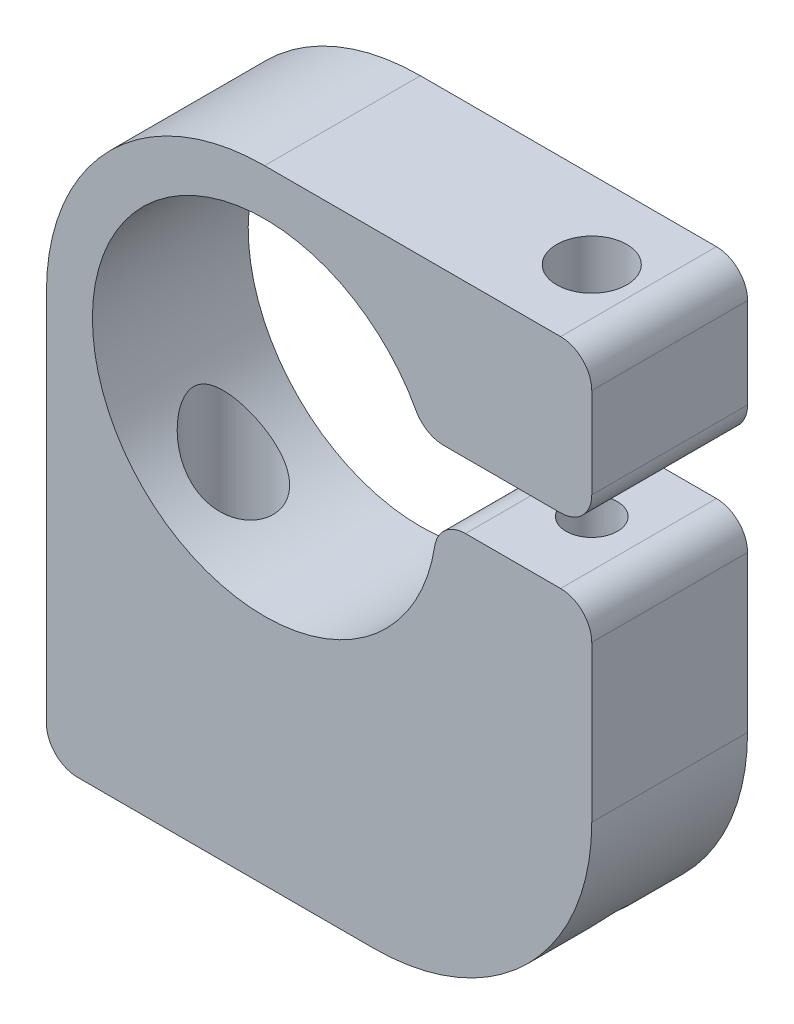
from build123d import *

# Parameters (mm, degrees)
EXTRUDE_1_DEPTH            = 10
HOLE_WIZARD_M41_D          = 4.5
HOLE_WIZARD_M41_DEPTH      = 9.8
M4X0_71_D                  = 3.3
HOLE_WIZARD_1_4_201_REACH  = 48.271
HOLE_WIZARD_1_4_201_BORE_R = 2.5527
FILLET_1_R                 = 2


with BuildPart() as part:
    # Эскиз1 → Бобышка-Вытянуть1 (new body)
    with BuildSketch(Plane.XY):
        with BuildLine():
            Line((10.220689801, 4.2), (21, 4.2))
            Line((21, 4.2), (21, 14))
            Line((21, 14), (0, 14))
            ThreePointArc((0, 14), (-9.899494937, 9.899494937), (-14, 0))
            Line((-14, 0), (-14, -26))
            Line((-14, -26), (7, -26))
            ThreePointArc((7, -26), (16.899494937, -21.899494937), (21, -12))
            Line((21, -12), (21, 0))
            Line((21, 0), (11.05, 0))
            ThreePointArc((11.05, 0), (-10.840690068, -2.140546391), (10.220689801, 4.2))
        make_face()
    extrude(amount=EXTRUDE_1_DEPTH)

    # Отверстие с зазором M41
    with Locations(Plane(origin=(0, 14, 0), x_dir=(1, 0, 0), z_dir=(0, 1, 0))):
        with Locations((16, -5)):
            Hole(HOLE_WIZARD_M41_D / 2, depth=HOLE_WIZARD_M41_DEPTH)

    # Отверстие обработанное метчиком M4x0.71 (through all)
    with Locations(Plane(origin=(0, 0, 0), x_dir=(1, 0, 0), z_dir=(0, 1, 0))):
        with Locations((16, -5)):
            Hole(M4X0_71_D / 2)

    # Отверстие обработанное метчиком 1/4-201 bore → Отверстие обработанное метчиком 1/4-201 (cut, up to next)
    with BuildSketch(Plane(origin=(0, -26, 0), x_dir=(-1, 0, 0), z_dir=(0, -1, 0)), mode=Mode.PRIVATE) as hole_wizard_1_4_201_sk1:
        with Locations((7, -5)):
            Circle(HOLE_WIZARD_1_4_201_BORE_R)
    hole_wizard_1_4_201_tool1 = extrude(hole_wizard_1_4_201_sk1.sketch, amount=-HOLE_WIZARD_1_4_201_REACH, mode=Mode.PRIVATE) & part.part
    add(hole_wizard_1_4_201_tool1.solids().sort_by_distance((-7, -26, 5))[0], mode=Mode.SUBTRACT)

    # Скругление1
    fillet_1_edges = [part.edges().sort_by_distance(p)[0] for p in [
        (11.05, 0, 5),
        (21, 0, 5),
        (-14, -26, 5),
        (21, 14, 5),
        (21, 4.2, 5),
        (10.220689801, 4.2, 5),
    ]]
    fillet(fillet_1_edges, radius=FILLET_1_R)


solid = part.part
